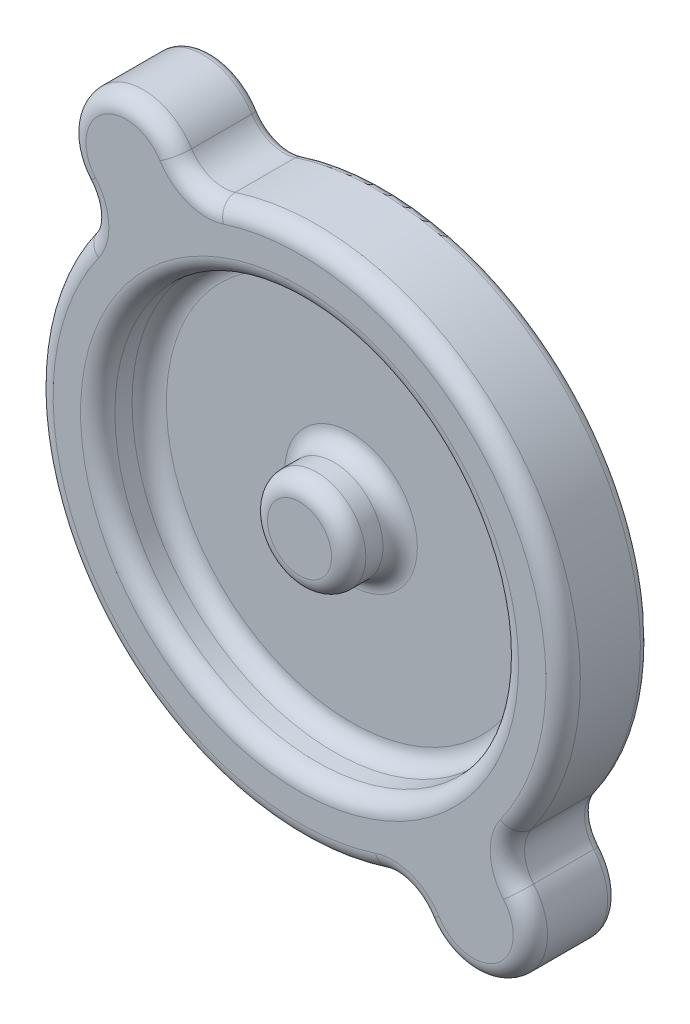
from build123d import *

# Parameters (mm, degrees)
EXTRUDE1_DEPTH = 6.35
SKETCH3_R      = 14.931587509
SKETCH3_R_2    = 3.633957754
EXTRUDE2_DEPTH = 3.81
FILLET1_R      = 1.27
FILLET2_R      = 1.27
FILLET3_R      = 0.635
SCALE1_SCALE   = 1.1


with BuildPart() as part:
    # Sketch2 → Extrude1 (new body)
    with BuildSketch(Plane.XY):
        with BuildLine():
            ThreePointArc((-9.248035812, 19.726828474), (-7.837681185, 18.580494802), (-6.020518287, 18.547327558))
            ThreePointArc((-6.020518287, 18.547327558), (15.718976408, 11.539661203), (15.891621368, -11.300724326))
            ThreePointArc((15.891621368, -11.300724326), (15.378845284, -13.044353228), (16.049981911, -14.733363795))
            ThreePointArc((16.049981911, -14.733363795), (15.346019988, -20.903882871), (9.248035812, -19.726828474))
            ThreePointArc((9.248035812, -19.726828474), (7.837681185, -18.580494802), (6.020518287, -18.547327558))
            ThreePointArc((6.020518287, -18.547327558), (-15.718976408, -11.539661203), (-15.891621368, 11.300724326))
            ThreePointArc((-15.891621368, 11.300724326), (-15.378845284, 13.044353229), (-16.049981911, 14.733363795))
            ThreePointArc((-16.049981911, 14.733363795), (-15.346019988, 20.903882871), (-9.248035812, 19.726828474))
        make_face()
    extrude(amount=EXTRUDE1_DEPTH)

    # Sketch3 → Extrude2 (cut)
    with BuildSketch(Plane.XY.offset(6.35)):
        Circle(SKETCH3_R)
        Circle(SKETCH3_R_2, mode=Mode.SUBTRACT)
    extrude(amount=-EXTRUDE2_DEPTH, mode=Mode.SUBTRACT)

    # Fillet1
    fillet1_edges = [part.edges().sort_by_distance(p)[0] for p in [
        (-14.931587509, 0, 2.54),
        (-3.633957754, 0, 2.54),
        (-14.931587509, 0, 6.35),
        (-3.633957754, 0, 6.35),
    ]]
    fillet(fillet1_edges, radius=FILLET1_R)

    # Fillet2
    fillet2_edges = [part.edges().sort_by_distance(p)[0] for p in [
        (-15.718976408, -11.539661203, 6.35),
        (7.837681185, -18.580494802, 6.35),
        (15.346019988, -20.903882871, 6.35),
        (15.378845284, -13.044353228, 6.35),
        (15.718976408, 11.539661203, 6.35),
        (-7.837681185, 18.580494802, 6.35),
        (-15.346019988, 20.903882871, 6.35),
        (-15.378845284, 13.044353229, 6.35),
    ]]
    fillet(fillet2_edges, radius=FILLET2_R)

    # Fillet3
    fillet3_edges = [part.edges().sort_by_distance(p)[0] for p in [
        (-15.378845284, 13.044353229, 0),
        (-15.346019988, 20.903882871, 0),
        (-7.837681185, 18.580494802, 0),
        (15.718976408, 11.539661203, 0),
        (15.378845284, -13.044353228, 0),
        (15.346019988, -20.903882871, 0),
        (7.837681185, -18.580494802, 0),
        (-15.718976408, -11.539661203, 0),
    ]]
    fillet(fillet3_edges, radius=FILLET3_R)


with BuildPart() as part_1:
    # Scale1: scaled about (0, 0, 0)
    add(part.part.scale(SCALE1_SCALE))


solid = part_1.part
